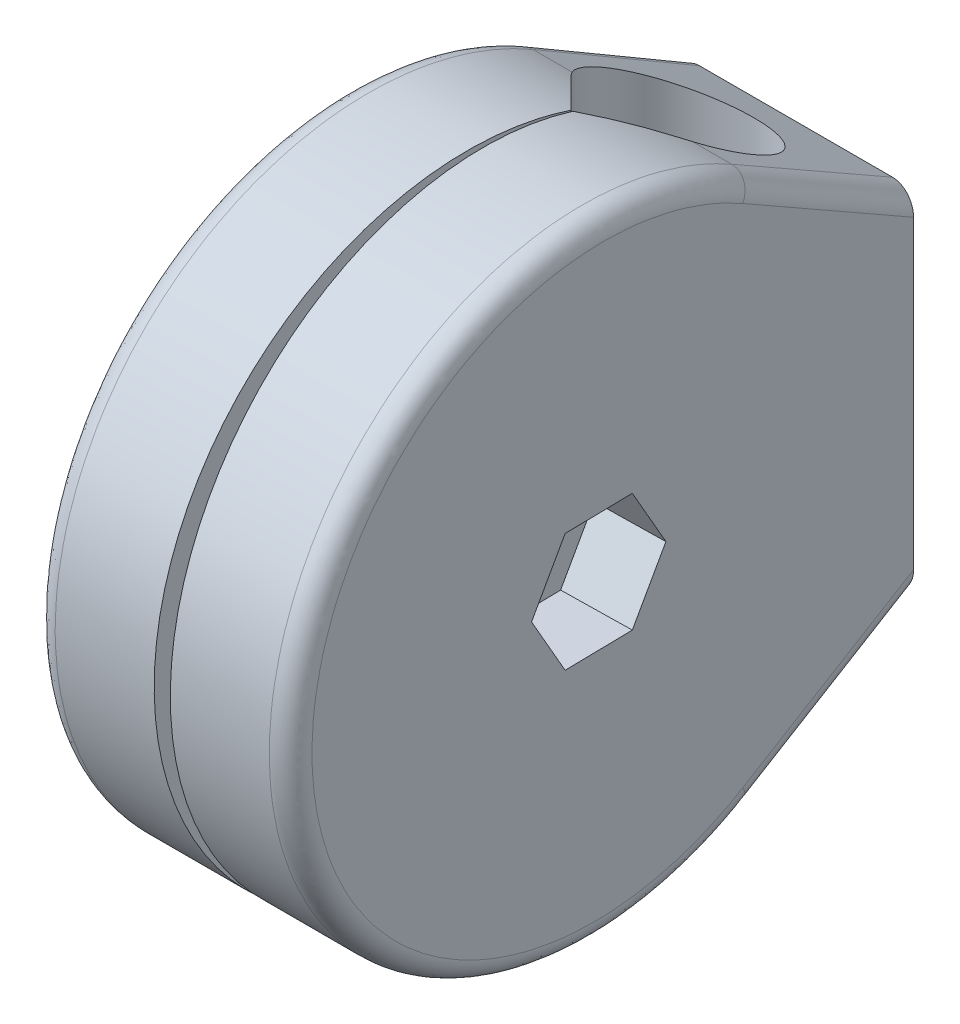
from build123d import *

# Parameters (mm, degrees)
BOSS_EXTRUDE1_DEPTH     = 16.668
CUT_EXTRUDE1_DEPTH      = 45.45
CUT_EXTRUDE1_DEPTH_BACK = 45.45
DRAFT1_ANGLE            = 1
CUT_EXTRUDE2_REACH      = 38.469
SKETCH3_R               = 5.5
CUT_EXTRUDE3_DEPTH      = 10
CUT_EXTRUDE4_REACH      = 38.469
SKETCH5_R               = 5.5
FILLET1_R               = 3


with BuildPart() as part:
    # Sketch1 → Boss-Extrude1 (new body, symmetric)
    with BuildSketch(Plane(origin=(0, 0, 0), x_dir=(0, 0, -1), z_dir=(1, 0, 0))):
        with BuildLine():
            Line((22.225, 38.494829198), (45.45, 25.085869196))
            Line((45.45, 25.085869196), (45.45, -25.085869196))
            Line((45.45, -25.085869196), (22.225, -38.494829198))
            ThreePointArc((22.225, -38.494829198), (-44.45, 0), (22.225, 38.494829198))
        make_face()
    extrude(amount=BOSS_EXTRUDE1_DEPTH, both=True)

    # Sketch2 → Cut-Extrude1 (cut, two sides)
    with BuildSketch(Plane(origin=(0, 0, 0), x_dir=(1, 0, 0), z_dir=(0, 1, 0))) as cut_extrude1_sk:
        with BuildLine():
            Line((-7.588316422, 21.130183578), (-0.129046134, 13.670913289))
            Line((-0.129046134, 13.670913289), (-1.143550449, -44.45))
            Line((-1.143550449, -44.45), (1.143550449, -44.45))
            Line((1.143550449, -44.45), (0.129046134, 13.670913289))
            Line((0.129046134, 13.670913289), (7.588316422, 21.130183578))
            ThreePointArc((7.588316422, 21.130183578), (0, 39.45), (-7.588316422, 21.130183578))
        make_face()
    extrude(amount=CUT_EXTRUDE1_DEPTH, mode=Mode.SUBTRACT)
    extrude(cut_extrude1_sk.sketch, amount=-CUT_EXTRUDE1_DEPTH_BACK, mode=Mode.SUBTRACT)

    # Draft1
    draft1_faces = [part.faces().sort_by_distance(p)[0] for p in [
        (16.668, 0, -1.658648034),
        (-16.668, 0, -1.658648034),
    ]]
    draft(draft1_faces, Plane(origin=(16.668, 25.085869196, -45.45), x_dir=(-1, 0, 0), z_dir=(0, 0, -1)), DRAFT1_ANGLE)

    # Sketch3 → Cut-Extrude2 (cut, up to next)
    with BuildSketch(Plane(origin=(17.456014215, 0, -0.304695862), x_dir=(-0.017452406, 0, -0.999847695), z_dir=(0.999847695, 0, -0.017452406)), mode=Mode.PRIVATE) as cut_extrude2_sk1:
        with Locations((-0.304742275, 0)):
            Circle(SKETCH3_R)
    cut_extrude2_tool1 = extrude(cut_extrude2_sk1.sketch, amount=-CUT_EXTRUDE2_REACH, mode=Mode.PRIVATE) & part.part
    add(cut_extrude2_tool1.solids().sort_by_distance((17.461333, 0, 0))[0], mode=Mode.SUBTRACT)

    # Sketch4 → Cut-Extrude3 (cut)
    with BuildSketch(Plane(origin=(17.456014215, 0, -0.304695862), x_dir=(-0.017452406, 0, -0.999847695), z_dir=(0.999847695, 0, -0.017452406))):
        Polygon((9.394742247, 0), (4.544999986, 8.4), (-5.154484536, 8.4), (-10.004226798, 0), (-5.154484536, -8.4), (4.544999986, -8.4), align=None)
    extrude(amount=-CUT_EXTRUDE3_DEPTH, mode=Mode.SUBTRACT)

    # Sketch5 → Cut-Extrude4 (cut, up to next)
    with BuildSketch(Plane(origin=(-17.456014215, 0, -0.304695862), x_dir=(-0.017452406, 0, 0.999847695), z_dir=(-0.999847695, 0, -0.017452406)), mode=Mode.PRIVATE) as cut_extrude4_sk1:
        with Locations((0.304742275, 0)):
            Circle(SKETCH5_R)
    cut_extrude4_tool1 = extrude(cut_extrude4_sk1.sketch, amount=-CUT_EXTRUDE4_REACH, mode=Mode.PRIVATE) & part.part
    add(cut_extrude4_tool1.solids().sort_by_distance((-17.461333, 0, 0))[0], mode=Mode.SUBTRACT)

    # Fillet1
    fillet1_edges = [part.edges().sort_by_distance(p)[0] for p in [
        (16.870696941, 31.790349197, -33.8375),
        (18.237210337, 0.000220739, 44.449999999),
        (-16.870696941, 31.790349197, -33.8375),
        (-16.870697084, -31.790353899, -33.837491856),
        (-18.237210337, 9.404e-06, 44.45),
        (16.870700278, -31.790459554, -33.837308856),
    ]]
    fillet(fillet1_edges, radius=FILLET1_R)


solid = part.part
